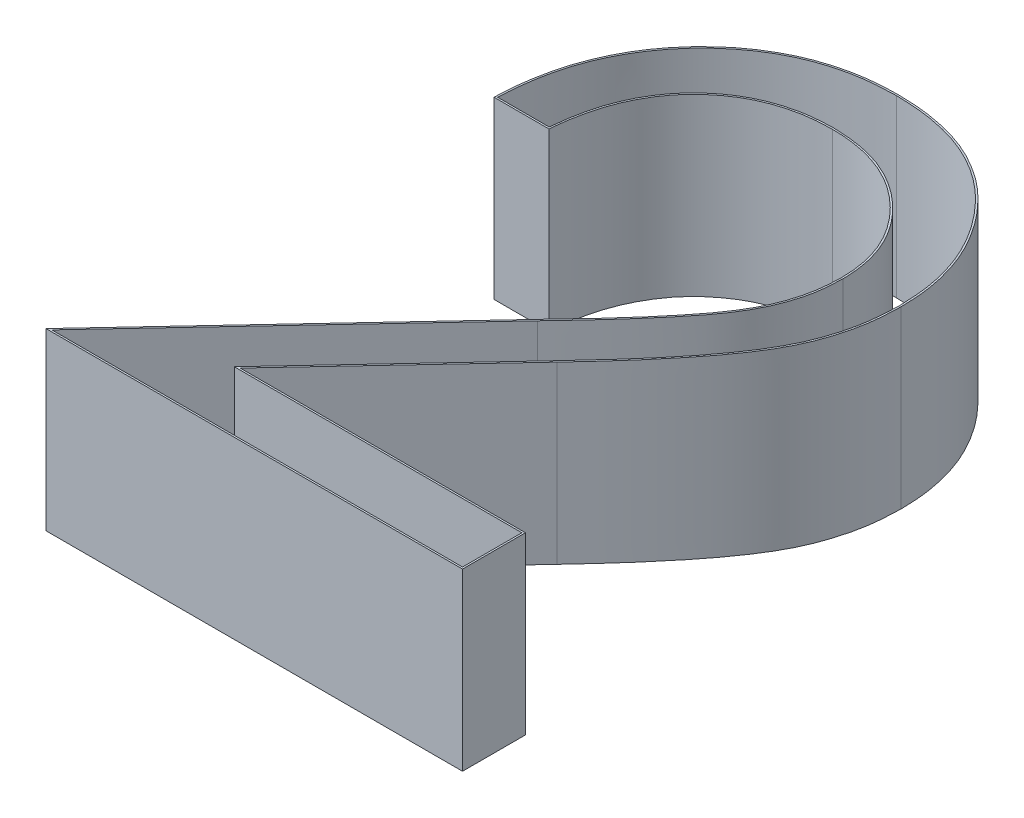
from build123d import *

# Parameters (mm, degrees)
BOSS_EXTRUDE1_DEPTH = 1
CUT_EXTRUDE1_DEPTH  = 1


with BuildPart() as part:
    # Sketch1 → Boss-Extrude1 (new body)
    with BuildSketch(Plane(origin=(0, 0, 0), x_dir=(1, 0, 0), z_dir=(0, 1, 0))):
        with BuildLine():
            Line((0.583333333, 2.423076923), (0.269230769, 2.423076923))
            add(Edge.make_bspline(
                [(0.269230769, 2.423076923), (0.271277922, 2.464747811), (0.275298476, 2.546588325), (0.294126766, 2.665912232), (0.321067643, 2.779967031), (0.359159097, 2.887836945), (0.406465375, 2.990475752), (0.463195402, 3.087475767), (0.530389252, 3.178466956), (0.606595986, 3.262605799), (0.689364626, 3.33979337), (0.778670565, 3.406448613), (0.872515592, 3.462766284), (0.970614991, 3.509847526), (1.074075555, 3.545187372), (1.181958413, 3.571409012), (1.294737549, 3.587185357), (1.371577571, 3.588881143), (1.410657051, 3.58974359)],
                knots=[0, 0, 0, 0, 0.000125083, 0.00024566, 0.000361805, 0.000476223, 0.000588214, 0.000700404, 0.000812728, 0.00092691, 0.001040529, 0.001151727, 0.001260545, 0.001368429, 0.001477521, 0.001587884, 0.001701119, 0.00181831, 0.00181831, 0.00181831, 0.00181831], degree=3))
            add(Edge.make_bspline(
                [(1.410657051, 3.58974359), (1.449035125, 3.588845133), (1.52444667, 3.587079698), (1.634508684, 3.571918669), (1.739285979, 3.548173078), (1.838573745, 3.514857661), (1.93157981, 3.470073234), (2.019002855, 3.416275695), (2.101883665, 3.354055864), (2.176490449, 3.28080205), (2.244998528, 3.202599666), (2.304100783, 3.119111762), (2.354713947, 3.032882477), (2.396901627, 2.943254275), (2.427957766, 2.849383247), (2.451535974, 2.752636044), (2.464863387, 2.652011233), (2.466908811, 2.583904677), (2.467948718, 2.549278846)],
                knots=[0, 0, 0, 0, 0.000115089, 0.000226145, 0.000332614, 0.000437044, 0.000539592, 0.000641561, 0.000744629, 0.00084975, 0.000954621, 0.001056175, 0.001156101, 0.001254284, 0.001352726, 0.001452208, 0.001552655, 0.001656537, 0.001656537, 0.001656537, 0.001656537], degree=3))
            add(Edge.make_bspline(
                [(2.467948718, 2.549278846), (2.466255455, 2.500531012), (2.462898644, 2.403890798), (2.434184267, 2.261875935), (2.389337756, 2.124282516), (2.335340399, 2.013545214), (2.280867955, 1.92431172), (2.231780448, 1.850843015), (2.174315637, 1.771737547), (2.107637139, 1.68726021), (2.033124266, 1.596749304), (1.950102103, 1.500259509), (1.857978621, 1.398787739), (1.79332012, 1.329482138), (1.759815705, 1.293569712)],
                knots=[0, 0, 0, 0, 0.000146118, 0.000289672, 0.0004329, 0.00057934, 0.000657978, 0.000746456, 0.000844345, 0.000951219, 0.001069268, 0.00119604, 0.001333047, 0.001480391, 0.001480391, 0.001480391, 0.001480391], degree=3))
            Line((1.759815705, 1.293569712), (0.884114583, 0.358974359))
            Line((0.884114583, 0.358974359), (2.512820513, 0.358974359))
            Line((2.512820513, 0.358974359), (2.512820513, 0))
            Line((2.512820513, 0), (0.134615385, 0))
            Line((0.134615385, 0), (1.491987179, 1.448517628))
            add(Edge.make_bspline(
                [(1.491987179, 1.448517628), (1.525035066, 1.483015935), (1.588513293, 1.549280121), (1.67829587, 1.646023081), (1.758934859, 1.735772622), (1.830952251, 1.818359171), (1.892785757, 1.894990738), (1.947657989, 1.963185442), (1.99162358, 2.025939892), (2.039338975, 2.098680506), (2.085552957, 2.187492823), (2.125265313, 2.296026513), (2.149480161, 2.407753765), (2.152384997, 2.483255802), (2.153846154, 2.521233974)],
                knots=[0, 0, 0, 0, 0.000143319, 0.000275286, 0.00039593, 0.000505287, 0.000603949, 0.000691331, 0.000767782, 0.00083371, 0.000952247, 0.001067137, 0.001179618, 0.001293462, 0.001293462, 0.001293462, 0.001293462], degree=3))
            add(Edge.make_bspline(
                [(2.153846154, 2.521233974), (2.153210412, 2.545115373), (2.151957486, 2.592181023), (2.140899788, 2.661186782), (2.124189282, 2.727751596), (2.100244024, 2.792080215), (2.068637284, 2.853525867), (2.030163904, 2.912163347), (1.98577384, 2.968852313), (1.934422571, 3.022005611), (1.878011051, 3.070686816), (1.818416802, 3.113810902), (1.755366698, 3.149850012), (1.689126575, 3.179393509), (1.619881106, 3.202568891), (1.547496361, 3.21862747), (1.472172345, 3.228709954), (1.420738849, 3.230074126), (1.39453125, 3.230769231)],
                knots=[0, 0, 0, 0, 7.16e-05, 0.00014111, 0.00020913, 0.00027724, 0.000346538, 0.000415963, 0.000487357, 0.000562233, 0.000637292, 0.000710646, 0.000782564, 0.000854749, 0.000927915, 0.001001225, 0.001076884, 0.001155488, 0.001155488, 0.001155488, 0.001155488], degree=3))
            add(Edge.make_bspline(
                [(1.39453125, 3.230769231), (1.367160417, 3.230054199), (1.313408621, 3.228649993), (1.234489588, 3.218827329), (1.159203811, 3.201881489), (1.087361908, 3.178704814), (1.018842322, 3.149246266), (0.953978278, 3.112554521), (0.892915389, 3.068771028), (0.835538865, 3.019130471), (0.782674886, 2.96386287), (0.73622801, 2.902252907), (0.695643996, 2.835425492), (0.660234763, 2.763560941), (0.631479073, 2.686007161), (0.609505922, 2.603039456), (0.592119075, 2.515018075), (0.586310555, 2.45423299), (0.583333333, 2.423076923)],
                knots=[0, 0, 0, 0, 8.2106e-05, 0.000161243, 0.000238127, 0.000313291, 0.000387401, 0.000461495, 0.000536397, 0.000612445, 0.000688819, 0.000765383, 0.000843422, 0.000923066, 0.001005373, 0.001091093, 0.001180334, 0.001274175, 0.001274175, 0.001274175, 0.001274175], degree=3))
        make_face()
    extrude(amount=BOSS_EXTRUDE1_DEPTH)

    # Sketch2 → Cut-Extrude1 (cut)
    with BuildSketch(Plane(origin=(0, 1, 0), x_dir=(1, 0, 0), z_dir=(0, 1, 0))):
        with BuildLine():
            Line((1.499246476, 1.441639719), (0.157690573, 0.01))
            Line((0.157690573, 0.01), (2.502820513, 0.01))
            Line((2.502820513, 0.01), (2.502820513, 0.348974359))
            Line((2.502820513, 0.348974359), (0.861040948, 0.348974359))
            Line((0.861040948, 0.348974359), (1.752511092, 1.300399261))
            add(Edge.make_bspline(
                [(1.752511092, 1.300399261), (1.92019697, 1.480136967), (2.08755232, 1.661145886), (2.29766678, 1.964618692), (2.358912798, 2.070542306), (2.418283834, 2.245696082), (2.433647153, 2.305574746), (2.453268483, 2.426300304), (2.455806173, 2.487770835), (2.457943503, 2.549302346)],
                knots=[0, 0, 0, 0, 0.5, 0.5, 0.75, 0.75, 0.875, 0.875, 1, 1, 1, 1], degree=3))
            add(Edge.make_bspline(
                [(2.457943503, 2.549302346), (2.45587938, 2.618030396), (2.452157445, 2.68647691), (2.426629989, 2.820298903), (2.407466354, 2.88701935), (2.328327085, 3.076914797), (2.249203133, 3.190374076), (2.058148257, 3.386080544), (1.940715683, 3.463743928), (1.749990318, 3.535503572), (1.683671267, 3.552091986), (1.547903939, 3.5748072), (1.479348909, 3.578132712), (1.410650345, 3.579741007)],
                knots=[0, 0, 0, 0, 0.125, 0.125, 0.25, 0.25, 0.5, 0.5, 0.75, 0.75, 0.875, 0.875, 1, 1, 1, 1], degree=3))
            add(Edge.make_bspline(
                [(1.410650345, 3.579741007), (1.335656181, 3.578085941), (1.26103452, 3.574151236), (1.114971351, 3.546819935), (1.042086496, 3.5261683), (0.834777755, 3.440746363), (0.711089291, 3.353811959), (0.503196625, 3.139320883), (0.420216614, 3.010789714), (0.338363948, 2.803258772), (0.318277011, 2.730892076), (0.289920356, 2.583079518), (0.283457144, 2.508243423), (0.279735446, 2.433076923)],
                knots=[0, 0, 0, 0, 0.125, 0.125, 0.25, 0.25, 0.5, 0.5, 0.75, 0.75, 0.875, 0.875, 1, 1, 1, 1], degree=3))
            Line((0.279735446, 2.433076923), (0.57424482, 2.433076923))
            add(Edge.make_bspline(
                [(0.57424482, 2.433076923), (0.584441228, 2.539244155), (0.603431985, 2.642997232), (0.680269679, 2.839836895), (0.737538652, 2.933244181), (0.888287052, 3.085329241), (0.978180718, 3.146320865), (1.129237022, 3.20423895), (1.180802744, 3.218378659), (1.286281018, 3.236667748), (1.340512639, 3.239361467), (1.394533245, 3.240772695)],
                knots=[0, 0, 0, 0, 0.25, 0.25, 0.5, 0.5, 0.75, 0.75, 0.875, 0.875, 1, 1, 1, 1], degree=3))
            add(Edge.make_bspline(
                [(1.394533245, 3.240772695), (1.492536389, 3.238173355), (1.589061274, 3.226106511), (1.774054233, 3.157331824), (1.855979536, 3.105584661), (2.001702907, 2.972963881), (2.062163372, 2.894739386), (2.124034516, 2.761654337), (2.138692808, 2.715301689), (2.158896392, 2.619554918), (2.162544042, 2.570280335), (2.163851273, 2.521174743)],
                knots=[0, 0, 0, 0, 0.25, 0.25, 0.5, 0.5, 0.75, 0.75, 0.875, 0.875, 1, 1, 1, 1], degree=3))
            add(Edge.make_bspline(
                [(2.163851273, 2.521174743), (2.161749334, 2.466541455), (2.158842644, 2.41208439), (2.137879239, 2.306487783), (2.121782923, 2.254918957), (2.059169767, 2.103349167), (1.998493532, 2.012295954), (1.797596813, 1.757688682), (1.649385086, 1.598367676), (1.499246476, 1.441639719)],
                knots=[0, 0, 0, 0, 0.125, 0.125, 0.25, 0.25, 0.5, 0.5, 1, 1, 1, 1], degree=3))
        make_face()
    extrude(amount=-CUT_EXTRUDE1_DEPTH, mode=Mode.SUBTRACT)


solid = part.part
